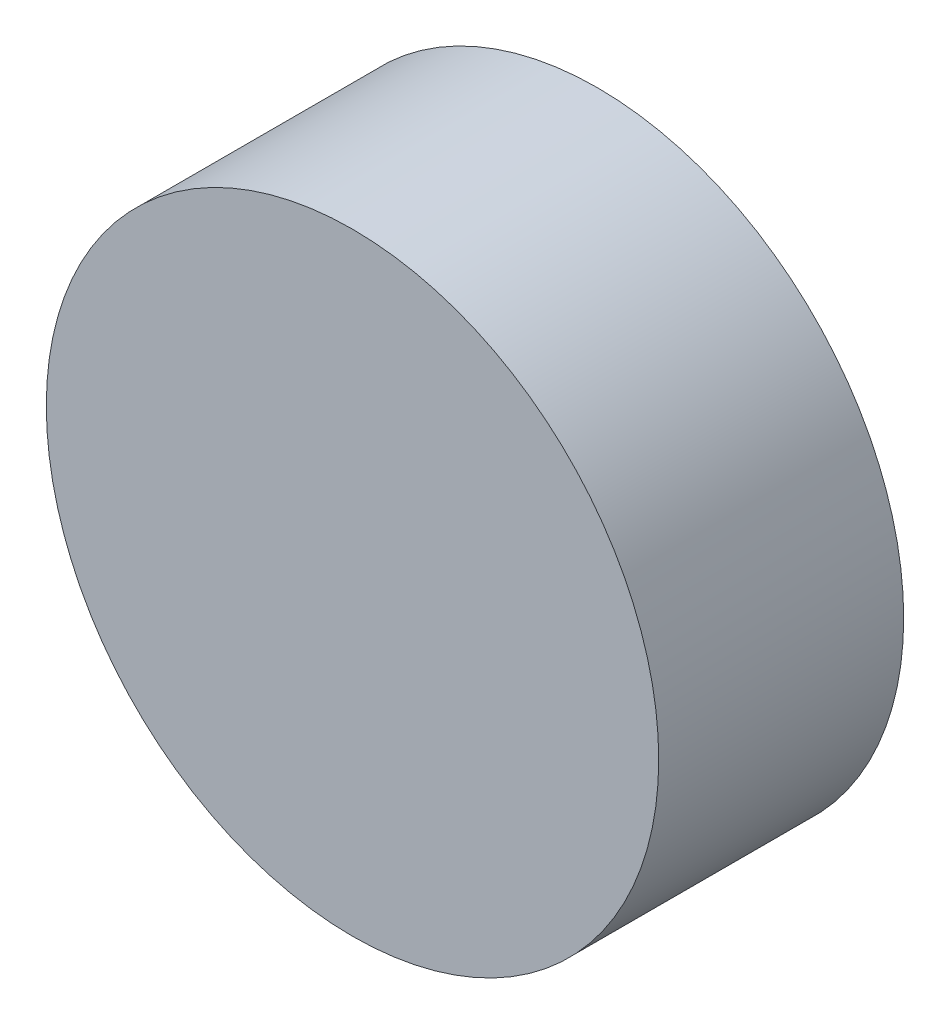
from build123d import *

# Parameters (mm, degrees)
CROQUIS1_R              = 2.5
SALIENTE_EXTRUIR1_DEPTH = 2


with BuildPart() as part:
    # Croquis1 → Saliente-Extruir1 (new body)
    with BuildSketch(Plane.XY):
        Circle(CROQUIS1_R)
    extrude(amount=SALIENTE_EXTRUIR1_DEPTH)


solid = part.part
